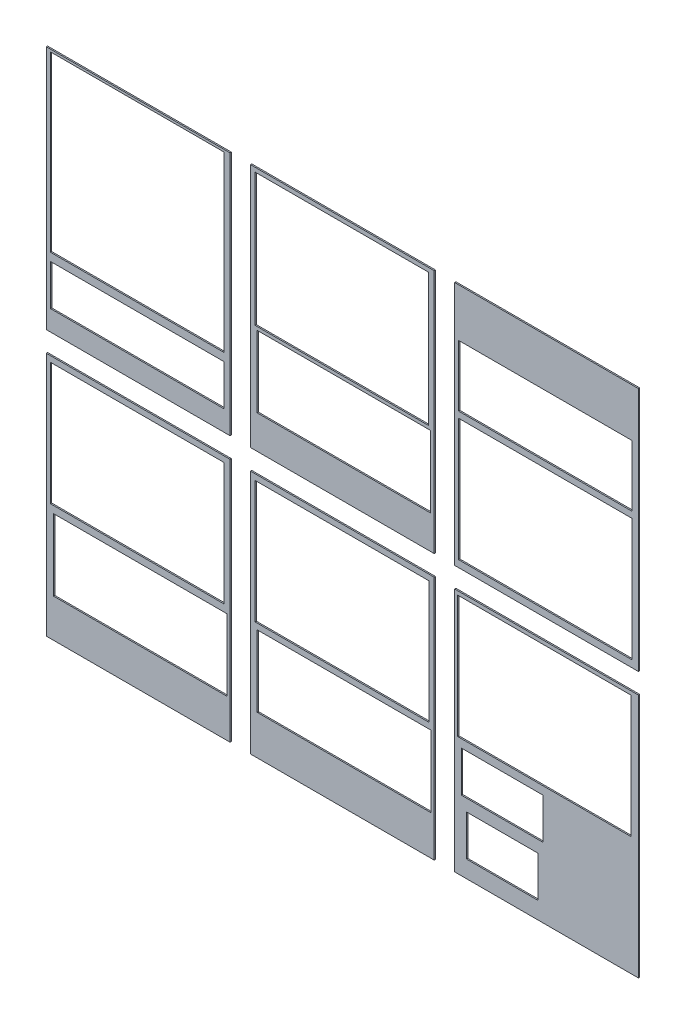
from build123d import *

# Parameters (mm, degrees)
SKETCH11_W                  = 457.2
SKETCH11_H                  = 609.6
BOSS_EXTRUDE1_DEPTH         = 3.175
BOSS_EXTRUDE1_2_DEPTH       = 3.175
BOSS_EXTRUDE1_3_DEPTH       = 3.175
BOSS_EXTRUDE1_4_DEPTH       = 3.175
BOSS_EXTRUDE1_5_DEPTH       = 3.175
BOSS_EXTRUDE1_6_DEPTH       = 3.175
FOLDER_INTER_WALLS_17X12_W  = 431.8
FOLDER_INTER_WALLS_17X12_H  = 304.8
CUT_EXTRUDE2_DEPTH          = 4.175
CUT_EXTRUDE2_DEPTH_BACK     = 1
BASE_PLATE_17X17_W          = 431.8
BASE_PLATE_17X17_H          = 431.8
CUT_EXTRUDE3_DEPTH          = 1
CUT_EXTRUDE3_DEPTH_BACK     = 4.175
TOP_BASE_LAYER_17X13_W      = 431.8
TOP_BASE_LAYER_17X13_H      = 330.2
CUT_EXTRUDE4_DEPTH          = 4.175
CUT_EXTRUDE4_DEPTH_BACK     = 1
BACK_WALL_17X4_W            = 431.8
BACK_WALL_17X4_H            = 101.6
CUT_EXTRUDE5_DEPTH          = 4.175
CUT_EXTRUDE5_DEPTH_BACK     = 1
ANGLED_FOLDER_WALL_2_17X7_W = 431.8
ANGLED_FOLDER_WALL_2_17X7_H = 177.8
CUT_EXTRUDE6_DEPTH          = 4.175
CUT_EXTRUDE6_DEPTH_BACK     = 1
FRONT_WALL_17X6_W           = 431.8
FRONT_WALL_17X6_H           = 152.4
CUT_EXTRUDE7_DEPTH          = 4.175
CUT_EXTRUDE7_DEPTH_BACK     = 1
LEFT_WALL_16X8_W            = 431.8
LEFT_WALL_16X8_H            = 177.8
CUT_EXTRUDE8_DEPTH          = 4.175
CUT_EXTRUDE8_DEPTH_BACK     = 1
RIGHT_WALL_12X8_W           = 431.8
RIGHT_WALL_12X8_H           = 177.8
CUT_EXTRUDE9_DEPTH          = 4.175
CUT_EXTRUDE9_DEPTH_BACK     = 1
ANGLED_FOLDER_WALL_3_8X4_W  = 203.2
ANGLED_FOLDER_WALL_3_8X4_H  = 101.6
CUT_EXTRUDE10_DEPTH         = 4.175
CUT_EXTRUDE10_DEPTH_BACK    = 1
ANGLED_FOLDER_WALL_1_7X4_W  = 177.8
ANGLED_FOLDER_WALL_1_7X4_H  = 101.6
CUT_EXTRUDE11_DEPTH         = 4.175
CUT_EXTRUDE11_DEPTH_BACK    = 1


with BuildPart() as part:
    # Sketch11 → Boss-Extrude1 (new body)
    with BuildSketch(Plane.XY):
        with Locations((2084.784911615, 277.838906703)):
            Rectangle(SKETCH11_W, SKETCH11_H)
    extrude(amount=BOSS_EXTRUDE1_DEPTH)

    # Top Base Layer, 17x13 → Cut-Extrude4 (cut, two sides)
    with BuildSketch(Plane.XY) as cut_extrude4_sk:
        with Locations((2083.501187973, 407.186637429)):
            Rectangle(TOP_BASE_LAYER_17X13_W, TOP_BASE_LAYER_17X13_H)
    extrude(amount=CUT_EXTRUDE4_DEPTH, mode=Mode.SUBTRACT)
    extrude(cut_extrude4_sk.sketch, amount=-CUT_EXTRUDE4_DEPTH_BACK, mode=Mode.SUBTRACT)

    # Angled Folder Wall 2, 17x7 → Cut-Extrude6 (cut, two sides)
    with BuildSketch(Plane.XY) as cut_extrude6_sk:
        with Locations((2088.373542002, 144.96438064)):
            Rectangle(ANGLED_FOLDER_WALL_2_17X7_W, ANGLED_FOLDER_WALL_2_17X7_H)
    extrude(amount=CUT_EXTRUDE6_DEPTH, mode=Mode.SUBTRACT)
    extrude(cut_extrude6_sk.sketch, amount=-CUT_EXTRUDE6_DEPTH_BACK, mode=Mode.SUBTRACT)


with BuildPart() as body_2:
    # Sketch11 → Boss-Extrude1 2 (new body)
    with BuildSketch(Plane.XY):
        with Locations((1576.784911615, 277.838906703)):
            Rectangle(SKETCH11_W, SKETCH11_H)
    extrude(amount=BOSS_EXTRUDE1_2_DEPTH)

    # Base Plate, 17x17 → Cut-Extrude3 (cut, two sides)
    with BuildSketch(Plane.XY.offset(3.175)) as cut_extrude3_sk:
        with Locations((1573.993628053, 360.86438064)):
            Rectangle(BASE_PLATE_17X17_W, BASE_PLATE_17X17_H)
    extrude(amount=CUT_EXTRUDE3_DEPTH, mode=Mode.SUBTRACT)
    extrude(cut_extrude3_sk.sketch, amount=-CUT_EXTRUDE3_DEPTH_BACK, mode=Mode.SUBTRACT)

    # Back Wall, 17x4 → Cut-Extrude5 (cut, two sides)
    with BuildSketch(Plane.XY) as cut_extrude5_sk:
        with Locations((1574.552650393, 74.379666893)):
            Rectangle(BACK_WALL_17X4_W, BACK_WALL_17X4_H)
    extrude(amount=CUT_EXTRUDE5_DEPTH, mode=Mode.SUBTRACT)
    extrude(cut_extrude5_sk.sketch, amount=-CUT_EXTRUDE5_DEPTH_BACK, mode=Mode.SUBTRACT)


with BuildPart() as body_3:
    # Sketch11 → Boss-Extrude1 3 (new body)
    with BuildSketch(Plane.XY):
        with Locations((2592.784911615, 277.838906703)):
            Rectangle(SKETCH11_W, SKETCH11_H)
    extrude(amount=BOSS_EXTRUDE1_3_DEPTH)


with BuildPart() as body_4:
    # Sketch11 → Boss-Extrude1 4 (new body)
    with BuildSketch(Plane.XY):
        with Locations((2084.784911615, -382.561093297)):
            Rectangle(SKETCH11_W, SKETCH11_H)
    extrude(amount=BOSS_EXTRUDE1_4_DEPTH)


with BuildPart() as body_5:
    # Sketch11 → Boss-Extrude1 5 (new body)
    with BuildSketch(Plane.XY):
        with Locations((2592.784911615, -382.561093297)):
            Rectangle(SKETCH11_W, SKETCH11_H)
    extrude(amount=BOSS_EXTRUDE1_5_DEPTH)


with BuildPart() as body_6:
    # Sketch11 → Boss-Extrude1 6 (new body)
    with BuildSketch(Plane.XY):
        with Locations((1576.784911615, -382.561093297)):
            Rectangle(SKETCH11_W, SKETCH11_H)
    extrude(amount=BOSS_EXTRUDE1_6_DEPTH)


with BuildPart() as cut_extrude2_tool:
    # Folder Inter Walls, 17x12 → Cut-Extrude2 (new body, two sides)
    with BuildSketch(Plane.XY) as cut_extrude2_sk:
        with Locations((2587.479266915, -239.528871664)):
            Rectangle(FOLDER_INTER_WALLS_17X12_W, FOLDER_INTER_WALLS_17X12_H)
        with Locations((2589.59064321, 142.630237721)):
            Rectangle(FOLDER_INTER_WALLS_17X12_W, FOLDER_INTER_WALLS_17X12_H)
        with Locations((1574.01864534, -244.513437782)):
            Rectangle(FOLDER_INTER_WALLS_17X12_W, FOLDER_INTER_WALLS_17X12_H)
        with Locations((2083.892472887, -244.513437782)):
            Rectangle(FOLDER_INTER_WALLS_17X12_W, FOLDER_INTER_WALLS_17X12_H)
    extrude(amount=CUT_EXTRUDE2_DEPTH)
    extrude(cut_extrude2_sk.sketch, amount=-CUT_EXTRUDE2_DEPTH_BACK)


with BuildPart() as body_3_1:
    add(body_3.part)

    # Cut-Extrude2: cut by cut_extrude2_tool
    add(cut_extrude2_tool.part, mode=Mode.SUBTRACT)

    # Front Wall, 17x6 → Cut-Extrude7 (cut, two sides)
    with BuildSketch(Plane.XY) as cut_extrude7_sk:
        with Locations((2589.59064321, 386.611241092)):
            Rectangle(FRONT_WALL_17X6_W, FRONT_WALL_17X6_H)
    extrude(amount=CUT_EXTRUDE7_DEPTH, mode=Mode.SUBTRACT)
    extrude(cut_extrude7_sk.sketch, amount=-CUT_EXTRUDE7_DEPTH_BACK, mode=Mode.SUBTRACT)


with BuildPart() as body_4_1:
    add(body_4.part)

    # Cut-Extrude2: cut by cut_extrude2_tool
    add(cut_extrude2_tool.part, mode=Mode.SUBTRACT)

    # Right wall, 12x8 → Cut-Extrude9 (cut, two sides)
    with BuildSketch(Plane.XY) as cut_extrude9_sk:
        with Locations((2088.87186834, -500.312959525)):
            Rectangle(RIGHT_WALL_12X8_W, RIGHT_WALL_12X8_H)
    extrude(amount=CUT_EXTRUDE9_DEPTH, mode=Mode.SUBTRACT)
    extrude(cut_extrude9_sk.sketch, amount=-CUT_EXTRUDE9_DEPTH_BACK, mode=Mode.SUBTRACT)


with BuildPart() as body_5_1:
    add(body_5.part)

    # Cut-Extrude2: cut by cut_extrude2_tool
    add(cut_extrude2_tool.part, mode=Mode.SUBTRACT)

    # Angled Folder Wall 3, 8x4 → Cut-Extrude10 (cut, two sides)
    with BuildSketch(Plane.XY) as cut_extrude10_sk:
        with Locations((2482.71694262, -462.882476624)):
            Rectangle(ANGLED_FOLDER_WALL_3_8X4_W, ANGLED_FOLDER_WALL_3_8X4_H)
    extrude(amount=CUT_EXTRUDE10_DEPTH, mode=Mode.SUBTRACT)
    extrude(cut_extrude10_sk.sketch, amount=-CUT_EXTRUDE10_DEPTH_BACK, mode=Mode.SUBTRACT)

    # Angled folder wall 1, 7x4 → Cut-Extrude11 (cut, two sides)
    with BuildSketch(Plane.XY) as cut_extrude11_sk:
        with Locations((2482.71694262, -594.201232774)):
            Rectangle(ANGLED_FOLDER_WALL_1_7X4_W, ANGLED_FOLDER_WALL_1_7X4_H)
    extrude(amount=CUT_EXTRUDE11_DEPTH, mode=Mode.SUBTRACT)
    extrude(cut_extrude11_sk.sketch, amount=-CUT_EXTRUDE11_DEPTH_BACK, mode=Mode.SUBTRACT)


with BuildPart() as body_6_1:
    add(body_6.part)

    # Cut-Extrude2: cut by cut_extrude2_tool
    add(cut_extrude2_tool.part, mode=Mode.SUBTRACT)

    # Left Wall, 16x8 → Cut-Extrude8 (cut, two sides)
    with BuildSketch(Plane.XY) as cut_extrude8_sk:
        with Locations((1581.923382741, -503.25007721)):
            Rectangle(LEFT_WALL_16X8_W, LEFT_WALL_16X8_H)
    extrude(amount=CUT_EXTRUDE8_DEPTH, mode=Mode.SUBTRACT)
    extrude(cut_extrude8_sk.sketch, amount=-CUT_EXTRUDE8_DEPTH_BACK, mode=Mode.SUBTRACT)


solid = Compound([part.part, body_2.part, body_3_1.part, body_4_1.part, body_5_1.part, body_6_1.part])
